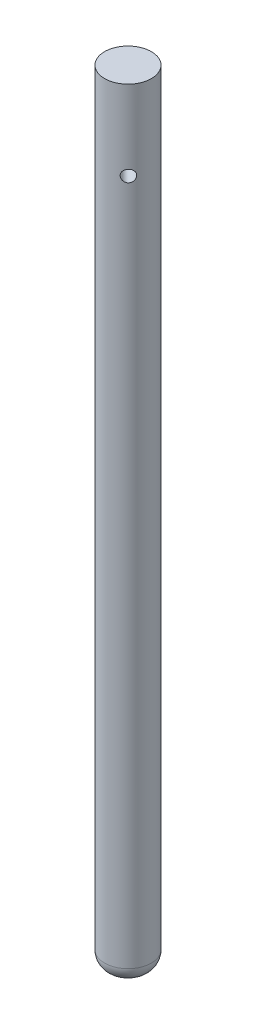
from build123d import *

# Parameters (mm, degrees)
SKETCH1_R                 = 2.99
BOSS_EXTRUDE1_DEPTH       = 100
F_1_5MM_DOWEL_HOLE5_D     = 1.5
F_1_5MM_DOWEL_HOLE5_DEPTH = 20
F_1_5MM_DOWEL_HOLE5_TIP   = 0.450645464
FILLET1_R                 = 2


with BuildPart() as part:
    # Sketch1 → Boss-Extrude1 (new body)
    with BuildSketch(Plane(origin=(0, 0, 0), x_dir=(1, 0, 0), z_dir=(0, 1, 0))):
        Circle(SKETCH1_R)
    extrude(amount=BOSS_EXTRUDE1_DEPTH)

    # Ø1.5mm Dowel Hole5
    with Locations(Plane(origin=(2.144246544, 89.818322141, 2.083820232), x_dir=(-0.696929844, 0, 0.717139312), z_dir=(0.717139312, 0, 0.696929844))):
        with Locations((0, 0)):
            Hole(F_1_5MM_DOWEL_HOLE5_D / 2, depth=F_1_5MM_DOWEL_HOLE5_DEPTH)
            with Locations((0, 0, -(F_1_5MM_DOWEL_HOLE5_DEPTH + F_1_5MM_DOWEL_HOLE5_TIP / 2))):  # 118° drill point
                Cone(0, F_1_5MM_DOWEL_HOLE5_D / 2, F_1_5MM_DOWEL_HOLE5_TIP, mode=Mode.SUBTRACT)

    # Fillet1
    fillet1_edges = [part.edges().sort_by_distance(p)[0] for p in [
        (-2.99, 0, 0),
    ]]
    fillet(fillet1_edges, radius=FILLET1_R)


solid = part.part
